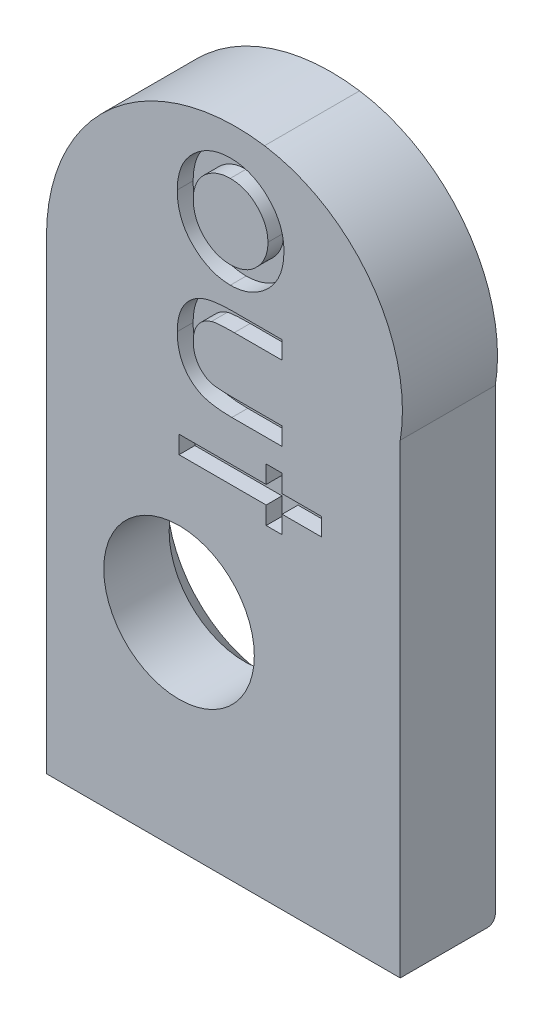
from build123d import *

# Parameters (mm, degrees)
BOSS_EXTRUDE1_DEPTH = 2.4
SKETCH3_R           = 1.9
CUT_EXTRUDE3_DEPTH  = 3.4
CHAMFER1_SIZE       = 0.75
CHAMFER1_SIZE2      = 0.804276533
FILLET1_R           = 0.2
CUT_EXTRUDE4_DEPTH  = 0.4
SCALE1_SCALE        = 1.15


with BuildPart() as part:
    # Sketch1 → Boss-Extrude1 (new body)
    with BuildSketch(Plane.XY):
        with BuildLine():
            Line((-3.345730544, 6.552967213), (-3.345730544, -5.2))
            Line((-3.345730544, -5.2), (5.58286968, -5.2))
            Line((5.58286968, -5.2), (5.58286968, 6.552967213))
            ThreePointArc((5.58286968, 6.552967213), (4.857648619, 9.631827975), (2.157036246, 11.27864976))
            ThreePointArc((2.157036246, 11.27864976), (-1.679748439, 10.179691557), (-3.345730544, 6.552967213))
        make_face()
    extrude(amount=BOSS_EXTRUDE1_DEPTH)

    # Sketch3 → Cut-Extrude3 (cut, through all)
    with BuildSketch(Plane.XY):
        Circle(SKETCH3_R)
    extrude(amount=CUT_EXTRUDE3_DEPTH, mode=Mode.SUBTRACT)

    # Chamfer1
    chamfer1_edges = [part.edges().sort_by_distance(p)[0] for p in [
        (-1.9, 0, 0),
    ]]
    chamfer1_side = [part.faces().sort_by_distance(p)[0] for p in [
        (-1.9, 0, 1.2),
    ]]
    chamfer(chamfer1_edges, length=CHAMFER1_SIZE, length2=CHAMFER1_SIZE2, reference=chamfer1_side[0])

    # Fillet1
    fillet1_edges = [part.edges().sort_by_distance(p)[0] for p in [
        (1.118569568, -5.2, 0),
    ]]
    fillet(fillet1_edges, radius=FILLET1_R)

    # Sketch4 → Cut-Extrude4 (cut)
    with BuildSketch(Plane.XY.offset(2.4)):
        with BuildLine():
            add(Edge.make_bspline(
                [(2.647435897, 9.21132169), (2.646016509, 9.159380611), (2.643237615, 9.057689783), (2.623603841, 8.908908503), (2.589766857, 8.767767325), (2.542661084, 8.63377309), (2.482190193, 8.506964867), (2.408088648, 8.387623244), (2.320035473, 8.276135537), (2.252484203, 8.208992323), (2.218349359, 8.175063677)],
                knots=[0, 0, 0, 0, 0.000155807, 0.00030504, 0.000449247, 0.0005905, 0.000730366, 0.000869863, 0.001011116, 0.001155406, 0.001155406, 0.001155406, 0.001155406], degree=3))
            add(Edge.make_bspline(
                [(2.218349359, 8.175063677), (2.184569367, 8.144899917), (2.118256635, 8.085686126), (2.010267576, 8.010306009), (1.900593289, 7.944088166), (1.786009732, 7.891762285), (1.668525675, 7.849338093), (1.54669492, 7.821707997), (1.421818335, 7.801898341), (1.337120039, 7.800147933), (1.294270833, 7.799262395)],
                knots=[0, 0, 0, 0, 0.000135744, 0.000266477, 0.000394416, 0.000519579, 0.000643759, 0.000768413, 0.000893843, 0.001022271, 0.001022271, 0.001022271, 0.001022271], degree=3))
            add(Edge.make_bspline(
                [(1.294270833, 7.799262395), (1.251202095, 7.80049602), (1.165845843, 7.802940892), (1.039756461, 7.821865609), (0.917025605, 7.851795394), (0.798213576, 7.894850209), (0.683191461, 7.95026075), (0.571259587, 8.01673651), (0.463907741, 8.096884941), (0.360824663, 8.186999842), (0.265726104, 8.287143015), (0.182468224, 8.396432417), (0.112009898, 8.513528248), (0.054012972, 8.638219072), (0.010188539, 8.771099555), (-0.022266192, 8.910882456), (-0.041432806, 9.058646195), (-0.04370713, 9.159615844), (-0.044871795, 9.21132169)],
                knots=[0, 0, 0, 0, 0.000129161, 0.000255978, 0.000381644, 0.000507616, 0.000634309, 0.00076417, 0.000897527, 0.001035639, 0.001174511, 0.001311093, 0.001446966, 0.001583735, 0.00172275, 0.001865952, 0.002013704, 0.002168781, 0.002168781, 0.002168781, 0.002168781], degree=3))
            add(Edge.make_bspline(
                [(-0.044871795, 9.21132169), (-0.043737537, 9.26070302), (-0.041514065, 9.357504723), (-0.021776537, 9.498962474), (0.008349879, 9.633849602), (0.053152229, 9.761197562), (0.109237379, 9.88200012), (0.17848455, 9.995494765), (0.26029152, 10.101970877), (0.354052874, 10.199876499), (0.455511014, 10.288907022), (0.562416146, 10.367214389), (0.673804765, 10.433670746), (0.789563416, 10.487861182), (0.910007707, 10.529332731), (1.034080697, 10.559712138), (1.162884473, 10.577449191), (1.25004648, 10.5800129), (1.294270833, 10.581313677)],
                knots=[0, 0, 0, 0, 0.000148071, 0.000290262, 0.000427684, 0.000562055, 0.000694418, 0.000826566, 0.000960069, 0.001096449, 0.001232582, 0.001364544, 0.001493444, 0.001621106, 0.001747271, 0.001874979, 0.002003781, 0.002136443, 0.002136443, 0.002136443, 0.002136443], degree=3))
            add(Edge.make_bspline(
                [(1.294270833, 10.581313677), (1.338025415, 10.580254315), (1.4242306, 10.57816716), (1.551337962, 10.561058059), (1.673469524, 10.532029213), (1.791613682, 10.492896265), (1.904870868, 10.441221437), (2.013880158, 10.378398153), (2.119044037, 10.304994531), (2.183595601, 10.247775356), (2.216245994, 10.218833709)],
                knots=[0, 0, 0, 0, 0.00013123, 0.000258548, 0.000383885, 0.00050738, 0.000631322, 0.000756636, 0.000884437, 0.001015239, 0.001015239, 0.001015239, 0.001015239], degree=3))
            add(Edge.make_bspline(
                [(2.216245994, 10.218833709), (2.250639716, 10.185164682), (2.318444964, 10.11878813), (2.406354353, 10.008305161), (2.481308848, 9.891739892), (2.541580307, 9.7679196), (2.590006813, 9.638289347), (2.623382156, 9.501575469), (2.643223129, 9.358440444), (2.646015323, 9.260931133), (2.647435897, 9.21132169)],
                knots=[0, 0, 0, 0, 0.000144276, 0.000284432, 0.000422523, 0.000559234, 0.000696769, 0.000836888, 0.000980563, 0.001129366, 0.001129366, 0.001129366, 0.001129366], degree=3))
        make_face()
        with BuildLine():
            add(Edge.make_bspline(
                [(2.243589744, 9.212723934), (2.242791365, 9.242683232), (2.241206141, 9.302169018), (2.228236003, 9.389787401), (2.207257982, 9.474945884), (2.176816373, 9.556722859), (2.138719646, 9.636304124), (2.09157422, 9.712377542), (2.036278699, 9.786124176), (1.973084348, 9.855958869), (1.90392265, 9.920894669), (1.829022543, 9.977284674), (1.750123928, 10.025231456), (1.667090995, 10.06484724), (1.579296834, 10.095094061), (1.487425402, 10.116494669), (1.391221946, 10.130531584), (1.325638139, 10.131898251), (1.292167468, 10.132595729)],
                knots=[0, 0, 0, 0, 8.9842e-05, 0.000178386, 0.00026511, 0.000352506, 0.000439682, 0.000529388, 0.000620534, 0.00071585, 0.000811596, 0.000904706, 0.000996571, 0.001088148, 0.001180166, 0.001274549, 0.001370828, 0.001471176, 0.001471176, 0.001471176, 0.001471176], degree=3))
            add(Edge.make_bspline(
                [(1.292167468, 10.132595729), (1.248596982, 10.130902326), (1.162893832, 10.127571402), (1.036872122, 10.10337894), (0.9171942, 10.061281852), (0.803986704, 10.004896535), (0.701008297, 9.935233572), (0.609744005, 9.855137944), (0.532171061, 9.765078783), (0.468968314, 9.665658077), (0.419795706, 9.559420828), (0.38473453, 9.447965014), (0.362835267, 9.331836543), (0.360272878, 9.252784467), (0.358974359, 9.212723934)],
                knots=[0, 0, 0, 0, 0.00013068, 0.000257047, 0.000383212, 0.0005102, 0.000635432, 0.000755144, 0.000873474, 0.000990754, 0.001107446, 0.001223638, 0.00134053, 0.001460626, 0.001460626, 0.001460626, 0.001460626], degree=3))
            add(Edge.make_bspline(
                [(0.358974359, 9.212723934), (0.360455055, 9.169387628), (0.363372844, 9.083991148), (0.386563068, 8.958916269), (0.423797639, 8.839470034), (0.475691764, 8.726489419), (0.541434524, 8.621637498), (0.621223572, 8.527877868), (0.713736138, 8.445705619), (0.816855702, 8.375345454), (0.92874096, 8.318526608), (1.046164237, 8.277733745), (1.16797497, 8.25299067), (1.250453797, 8.249663208), (1.292167468, 8.247980344)],
                knots=[0, 0, 0, 0, 0.000129937, 0.000256047, 0.000380227, 0.00050446, 0.000627979, 0.00075034, 0.000872496, 0.000998122, 0.001123858, 0.001247806, 0.001370045, 0.001495128, 0.001495128, 0.001495128, 0.001495128], degree=3))
            add(Edge.make_bspline(
                [(1.292167468, 8.247980344), (1.324466638, 8.248711582), (1.388181078, 8.250154048), (1.481922858, 8.263921162), (1.572187569, 8.286266018), (1.658576211, 8.318014618), (1.741373901, 8.358233372), (1.820285768, 8.407664952), (1.89533782, 8.466280076), (1.96632632, 8.532313866), (2.031196809, 8.604761769), (2.088053962, 8.681758466), (2.135869043, 8.762220274), (2.175922251, 8.845477259), (2.2057237, 8.93270066), (2.22754647, 9.023037493), (2.241444833, 9.116706794), (2.242868191, 9.180423576), (2.243589744, 9.212723934)],
                knots=[0, 0, 0, 0, 9.6846e-05, 0.000191042, 0.000283548, 0.000375376, 0.000466624, 0.000559225, 0.00065417, 0.000751898, 0.000849716, 0.000945493, 0.00103856, 0.001130136, 0.001222155, 0.001314493, 0.001408688, 0.001505535, 0.001505535, 0.001505535, 0.001505535], degree=3))
        make_face(mode=Mode.SUBTRACT)
        with BuildLine():
            Line((2.602564103, 7.260800857), (2.602564103, 6.812082908))
            Line((2.602564103, 6.812082908), (1.39453125, 6.812082908))
            add(Edge.make_bspline(
                [(1.39453125, 6.812082908), (1.360409421, 6.81195121), (1.294963184, 6.811698611), (1.200989926, 6.809719185), (1.115938164, 6.805941689), (1.039645717, 6.802431216), (0.972397988, 6.795587336), (0.913538224, 6.789341591), (0.863718774, 6.780253562), (0.833835778, 6.772722564), (0.8203125, 6.769314479)],
                knots=[0, 0, 0, 0, 0.000102366, 0.00019634, 0.000281949, 0.000357787, 0.000425389, 0.0004847, 0.000535307, 0.00057714, 0.00057714, 0.00057714, 0.00057714], degree=3))
            add(Edge.make_bspline(
                [(0.8203125, 6.769314479), (0.78401576, 6.756501928), (0.713856349, 6.73173604), (0.619535206, 6.675349269), (0.538368362, 6.607286304), (0.472899892, 6.525231078), (0.421262545, 6.433851532), (0.385917311, 6.33310441), (0.362273122, 6.225170957), (0.360092074, 6.150122214), (0.358974359, 6.111662235)],
                knots=[0, 0, 0, 0, 0.000115225, 0.000222723, 0.00032767, 0.000431364, 0.000535897, 0.000641024, 0.000750616, 0.000865814, 0.000865814, 0.000865814, 0.000865814], degree=3))
            add(Edge.make_bspline(
                [(0.358974359, 6.111662235), (0.36039748, 6.069721107), (0.363146553, 5.988702522), (0.38592072, 5.872157646), (0.423747703, 5.765473977), (0.477287866, 5.670241201), (0.542501708, 5.586763769), (0.618610024, 5.517796981), (0.702648981, 5.460141727), (0.765502132, 5.435552026), (0.797175481, 5.423160632)],
                knots=[0, 0, 0, 0, 0.000125738, 0.00024289, 0.000354666, 0.000463897, 0.000569235, 0.000670966, 0.000771111, 0.000872841, 0.000872841, 0.000872841, 0.000872841], degree=3))
            add(Edge.make_bspline(
                [(0.797175481, 5.423160632), (0.81043133, 5.419143686), (0.839848706, 5.410229281), (0.890085894, 5.402272317), (0.949565523, 5.393274635), (1.019398747, 5.387819484), (1.099039251, 5.381699756), (1.188852052, 5.378729326), (1.288415952, 5.376509533), (1.358071035, 5.376296817), (1.39453125, 5.376185472)],
                knots=[0, 0, 0, 0, 4.1509e-05, 9.2116e-05, 0.000152302, 0.000221999, 0.000302124, 0.000391936, 0.000491517, 0.000600895, 0.000600895, 0.000600895, 0.000600895], degree=3))
            Line((1.39453125, 5.376185472), (2.602564103, 5.376185472))
            Line((2.602564103, 5.376185472), (2.602564103, 4.927467523))
            Line((2.602564103, 4.927467523), (1.333533654, 4.927467523))
            add(Edge.make_bspline(
                [(1.333533654, 4.927467523), (1.291928332, 4.927917879), (1.211016153, 4.928793712), (1.093588996, 4.934198193), (0.983630601, 4.943921733), (0.88162571, 4.957806909), (0.787109744, 4.975409965), (0.700259241, 4.99587099), (0.621038806, 5.021236659), (0.548854542, 5.050853581), (0.48235351, 5.084800007), (0.420236856, 5.123118933), (0.36100772, 5.165266371), (0.305026809, 5.211967637), (0.253039704, 5.263796076), (0.203561547, 5.319115099), (0.158210363, 5.379618364), (0.116034079, 5.444109326), (0.077821404, 5.513033952), (0.045326796, 5.586640374), (0.016638663, 5.664188369), (-0.004969704, 5.74632681), (-0.023852052, 5.832261511), (-0.036118759, 5.922524584), (-0.042997046, 6.017136131), (-0.044236849, 6.081502511), (-0.044871795, 6.114466722)],
                knots=[0, 0, 0, 0, 0.000124817, 0.000242739, 0.000352554, 0.000455874, 0.000551445, 0.000640892, 0.000723375, 0.000800715, 0.000874715, 0.000947104, 0.00101948, 0.001092642, 0.001165522, 0.001239526, 0.001315107, 0.001392116, 0.001470566, 0.001551223, 0.001633287, 0.001718331, 0.001805789, 0.00189711, 0.001991321, 0.002090219, 0.002090219, 0.002090219, 0.002090219], degree=3))
            add(Edge.make_bspline(
                [(-0.044871795, 6.114466722), (-0.044619273, 6.145569907), (-0.044124781, 6.20647674), (-0.035817194, 6.295611112), (-0.024139549, 6.381101261), (-0.007606239, 6.462703335), (0.01447872, 6.54063823), (0.040844566, 6.614809876), (0.072405008, 6.68520613), (0.109185511, 6.751303571), (0.149787377, 6.813565091), (0.193939041, 6.872243084), (0.242775744, 6.926107217), (0.294244691, 6.976849125), (0.350420835, 7.022571534), (0.409607148, 7.064817329), (0.473376744, 7.101699526), (0.540561993, 7.136277604), (0.614578759, 7.165707202), (0.69605284, 7.191669611), (0.785848989, 7.213110009), (0.883986195, 7.230429291), (0.990179315, 7.244389667), (1.105048469, 7.254074346), (1.228078902, 7.259480794), (1.312962111, 7.260352165), (1.356670673, 7.260800857)],
                knots=[0, 0, 0, 0, 9.3273e-05, 0.000182649, 0.000268318, 0.000352057, 0.000432185, 0.000511135, 0.000588019, 0.000663336, 0.000737817, 0.000810875, 0.000883366, 0.000955755, 0.001027482, 0.001100429, 0.001173658, 0.001248284, 0.001326923, 0.00141229, 0.001504628, 0.001603647, 0.001711136, 0.00182584, 0.001949365, 0.002080492, 0.002080492, 0.002080492, 0.002080492], degree=3))
            Line((1.356670673, 7.260800857), (2.602564103, 7.260800857))
        make_face()
        Polygon((3.58974359, 3.895416241), (3.58974359, 3.446698293), (2.602564103, 3.446698293), (2.602564103, 2.997980344), (2.198717949, 2.997980344), (2.198717949, 3.446698293), (0, 3.446698293), (0, 3.895416241), (2.198717949, 3.895416241), (2.198717949, 4.34413419), (2.602564103, 4.34413419), (2.602564103, 3.895416241), align=None)
    extrude(amount=-CUT_EXTRUDE4_DEPTH, mode=Mode.SUBTRACT)


with BuildPart() as part_1:
    # Scale1: scaled about (1.270043316, 2.866904373, 1.203100921)
    add(part.part.scale(SCALE1_SCALE).moved(Location((-0.190506497, -0.430035656, -0.180465138))))


solid = part_1.part
